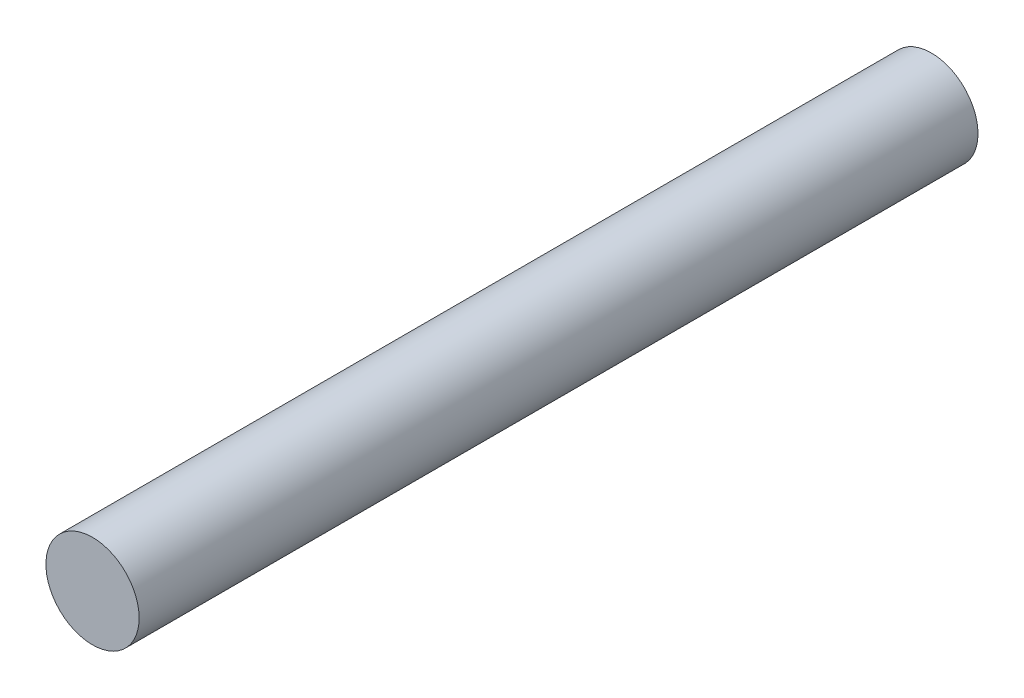
from build123d import *

# Parameters (mm, degrees)
SKETCH1_R           = 2.5
BOSS_EXTRUDE1_DEPTH = 45


with BuildPart() as part:
    # Sketch1 → Boss-Extrude1 (new body)
    with BuildSketch(Plane.XY):
        Circle(SKETCH1_R)
    extrude(amount=-BOSS_EXTRUDE1_DEPTH)


solid = part.part
